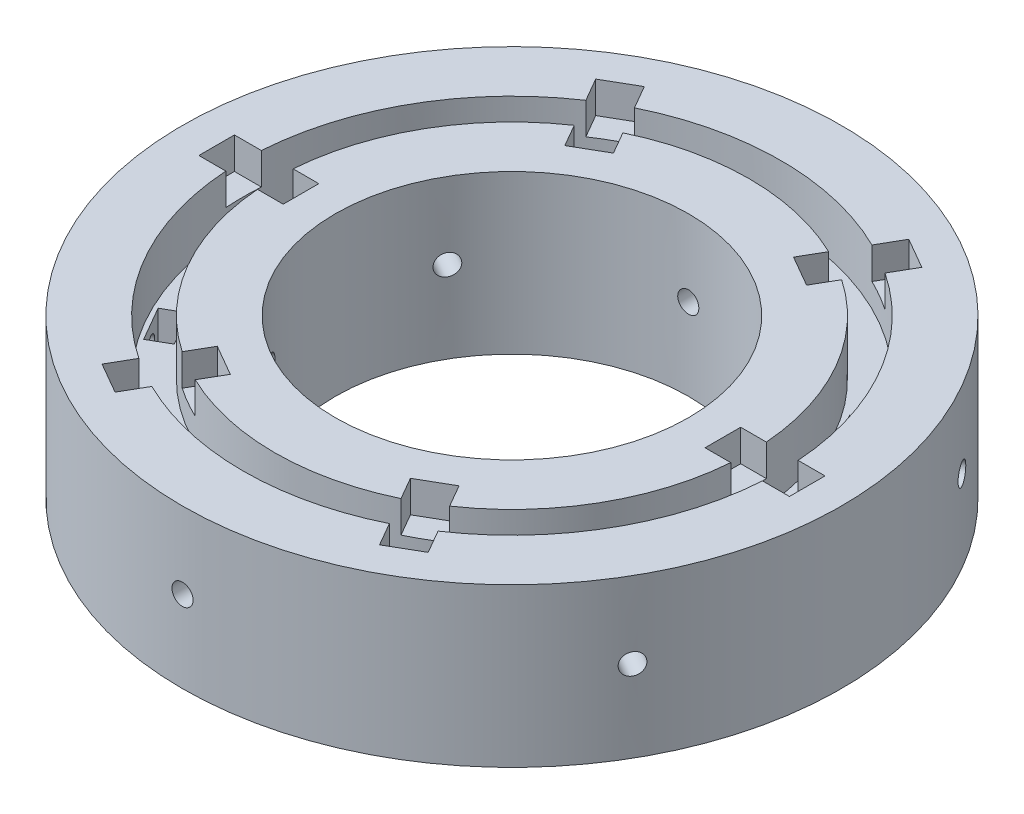
from build123d import *

# Parameters (mm, degrees)
SKETCH1_R           = 62.5
SKETCH1_R_2         = 33.5
BOSS_EXTRUDE1_DEPTH = 30
SKETCH2_W           = 16
SKETCH2_H           = 6.75
CUT_EXTRUDE2_DEPTH  = 6
SKETCH3_R           = 51
SKETCH3_R_2         = 45
CUT_EXTRUDE3_DEPTH  = 10.5
SKETCH6_W           = 7.5
SKETCH6_H           = 4.25
CUT_EXTRUDE4_DEPTH  = 8
CUT_EXTRUDE5_START  = -13.375
SKETCH8_R           = 2
CUT_EXTRUDE5_DEPTH  = 60.125
CIRPATTERN1_COUNT   = 6


with BuildPart() as part:
    # Sketch1 → Boss-Extrude1 (new body)
    with BuildSketch(Plane(origin=(0, 0, 0), x_dir=(1, 0, 0), z_dir=(0, 1, 0))):
        Circle(SKETCH1_R)
        Circle(SKETCH1_R_2, mode=Mode.SUBTRACT)
    extrude(amount=BOSS_EXTRUDE1_DEPTH)

    # Sketch2 → Cut-Extrude2 (cut)
    with BuildSketch(Plane(origin=(0, 30, 0), x_dir=(1, 0, 0), z_dir=(0, 1, 0))):
        with Locations((48, 0)):
            Rectangle(SKETCH2_W, SKETCH2_H)
        Polygon((22.922835738, -32.953516151), (17.077164262, -36.328516151), (25.077164262, -50.184922612), (30.922835738, -46.809922612), align=None)
        Polygon((-17.077164262, -36.328516151), (-22.922835738, -32.953516151), (-30.922835738, -46.809922612), (-25.077164262, -50.184922612), align=None)
        with Locations((-48, 0)):
            Rectangle(SKETCH2_W, SKETCH2_H)
        Polygon((-22.922835738, 32.953516151), (-17.077164262, 36.328516151), (-25.077164262, 50.184922612), (-30.922835738, 46.809922612), align=None)
        Polygon((17.077164262, 36.328516151), (22.922835738, 32.953516151), (30.922835738, 46.809922612), (25.077164262, 50.184922612), align=None)
    extrude(amount=-CUT_EXTRUDE2_DEPTH, mode=Mode.SUBTRACT)

    # Sketch3 → Cut-Extrude3 (cut)
    with BuildSketch(Plane(origin=(0, 30, 0), x_dir=(1, 0, 0), z_dir=(0, 1, 0))):
        Circle(SKETCH3_R)
        Circle(SKETCH3_R_2, mode=Mode.SUBTRACT)
    extrude(amount=-CUT_EXTRUDE3_DEPTH, mode=Mode.SUBTRACT)

    # Sketch6 → Cut-Extrude4 (cut)
    with BuildSketch(Plane(origin=(0, 19.5, 0), x_dir=(1, 0, 0), z_dir=(0, 1, 0))):
        with Locations((0, 48)):
            Rectangle(SKETCH6_W, SKETCH6_H)
        Polygon((41.534523365, 28.310095264), (37.853915399, 26.185095264), (41.603915399, 19.689904736), (45.284523365, 21.814904736), align=None)
        Polygon((45.284523365, -21.814904736), (41.603915399, -19.689904736), (37.853915399, -26.185095264), (41.534523365, -28.310095264), align=None)
        with Locations((0, -48)):
            Rectangle(SKETCH6_W, SKETCH6_H)
        Polygon((-41.534523365, -28.310095264), (-37.853915399, -26.185095264), (-41.603915399, -19.689904736), (-45.284523365, -21.814904736), align=None)
        Polygon((-45.284523365, 21.814904736), (-41.603915399, 19.689904736), (-37.853915399, 26.185095264), (-41.534523365, 28.310095264), align=None)
    extrude(amount=-CUT_EXTRUDE4_DEPTH, mode=Mode.SUBTRACT)

    # Sketch8 → Cut-Extrude5 (cut)
    with BuildSketch(Plane.XY.offset(-50.125).offset(CUT_EXTRUDE5_START)):
        with Locations((0, 15.5)):
            Circle(SKETCH8_R)
    cut_extrude5 = extrude(amount=CUT_EXTRUDE5_DEPTH, mode=Mode.SUBTRACT)

    # CirPattern1: Cut-Extrude5 ×6 about axis
    cirpattern1_axis = Axis((0, 19.5, 0), (0, 1, 0))
    for i in range(1, CIRPATTERN1_COUNT):
        add(cut_extrude5.rotate(cirpattern1_axis, i * 360 / CIRPATTERN1_COUNT), mode=Mode.SUBTRACT)


solid = part.part
